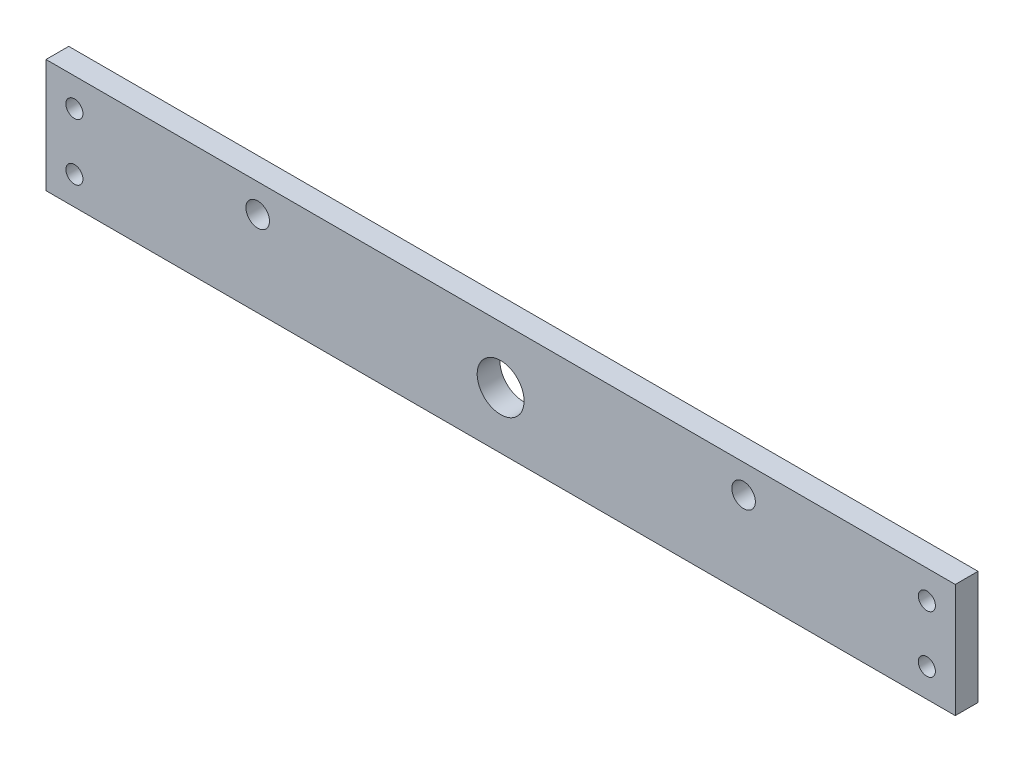
from build123d import *

# Parameters (mm, degrees)
SKETCH1_W           = 320
SKETCH1_H           = 40
BOSS_EXTRUDE1_DEPTH = 8
CUT_EXTRUDE1_REACH  = 10
SKETCH2_R           = 3
CUT_EXTRUDE2_REACH  = 10
SKETCH3_R           = 4.15
SKETCH3_R_2         = 8.25


with BuildPart() as part:
    # Sketch1 → Boss-Extrude1 (new body)
    with BuildSketch(Plane.XY):
        Rectangle(SKETCH1_W, SKETCH1_H)
    extrude(amount=BOSS_EXTRUDE1_DEPTH)

    # Sketch2 → Cut-Extrude1 (cut, up to next)
    with BuildSketch(Plane.XY.offset(8), mode=Mode.PRIVATE) as cut_extrude1_sk1:
        with Locations((-150, 10)):
            Circle(SKETCH2_R)
    cut_extrude1_tool1 = extrude(cut_extrude1_sk1.sketch, amount=-CUT_EXTRUDE1_REACH, mode=Mode.PRIVATE) & part.part
    add(cut_extrude1_tool1.solids().sort_by_distance((-150, 10, 8))[0], mode=Mode.SUBTRACT)
    # Sketch2 → Cut-Extrude1 (cut, up to next)
    with BuildSketch(Plane.XY.offset(8), mode=Mode.PRIVATE) as cut_extrude1_sk2:
        with Locations((-150, -10)):
            Circle(SKETCH2_R)
    cut_extrude1_tool2 = extrude(cut_extrude1_sk2.sketch, amount=-CUT_EXTRUDE1_REACH, mode=Mode.PRIVATE) & part.part
    add(cut_extrude1_tool2.solids().sort_by_distance((-150, -10, 8))[0], mode=Mode.SUBTRACT)
    # Sketch2 → Cut-Extrude1 (cut, up to next)
    with BuildSketch(Plane.XY.offset(8), mode=Mode.PRIVATE) as cut_extrude1_sk3:
        with Locations((150, -10)):
            Circle(SKETCH2_R)
    cut_extrude1_tool3 = extrude(cut_extrude1_sk3.sketch, amount=-CUT_EXTRUDE1_REACH, mode=Mode.PRIVATE) & part.part
    add(cut_extrude1_tool3.solids().sort_by_distance((150, -10, 8))[0], mode=Mode.SUBTRACT)
    # Sketch2 → Cut-Extrude1 (cut, up to next)
    with BuildSketch(Plane.XY.offset(8), mode=Mode.PRIVATE) as cut_extrude1_sk4:
        with Locations((150, 10)):
            Circle(SKETCH2_R)
    cut_extrude1_tool4 = extrude(cut_extrude1_sk4.sketch, amount=-CUT_EXTRUDE1_REACH, mode=Mode.PRIVATE) & part.part
    add(cut_extrude1_tool4.solids().sort_by_distance((150, 10, 8))[0], mode=Mode.SUBTRACT)

    # Sketch3 → Cut-Extrude2 (cut, up to next)
    with BuildSketch(Plane.XY.offset(8), mode=Mode.PRIVATE) as cut_extrude2_sk1:
        with Locations((-85.5, 10)):
            Circle(SKETCH3_R)
    cut_extrude2_tool1 = extrude(cut_extrude2_sk1.sketch, amount=-CUT_EXTRUDE2_REACH, mode=Mode.PRIVATE) & part.part
    add(cut_extrude2_tool1.solids().sort_by_distance((-85.5, 10, 8))[0], mode=Mode.SUBTRACT)
    # Sketch3 → Cut-Extrude2 (cut, up to next)
    with BuildSketch(Plane.XY.offset(8), mode=Mode.PRIVATE) as cut_extrude2_sk2:
        with Locations((85.5, 10)):
            Circle(SKETCH3_R)
    cut_extrude2_tool2 = extrude(cut_extrude2_sk2.sketch, amount=-CUT_EXTRUDE2_REACH, mode=Mode.PRIVATE) & part.part
    add(cut_extrude2_tool2.solids().sort_by_distance((85.5, 10, 8))[0], mode=Mode.SUBTRACT)
    # Sketch3 → Cut-Extrude2 (cut, up to next)
    with BuildSketch(Plane.XY.offset(8), mode=Mode.PRIVATE) as cut_extrude2_sk3:
        Circle(SKETCH3_R_2)
    cut_extrude2_tool3 = extrude(cut_extrude2_sk3.sketch, amount=-CUT_EXTRUDE2_REACH, mode=Mode.PRIVATE) & part.part
    add(cut_extrude2_tool3.solids().sort_by_distance((0, 0, 8))[0], mode=Mode.SUBTRACT)


solid = part.part
